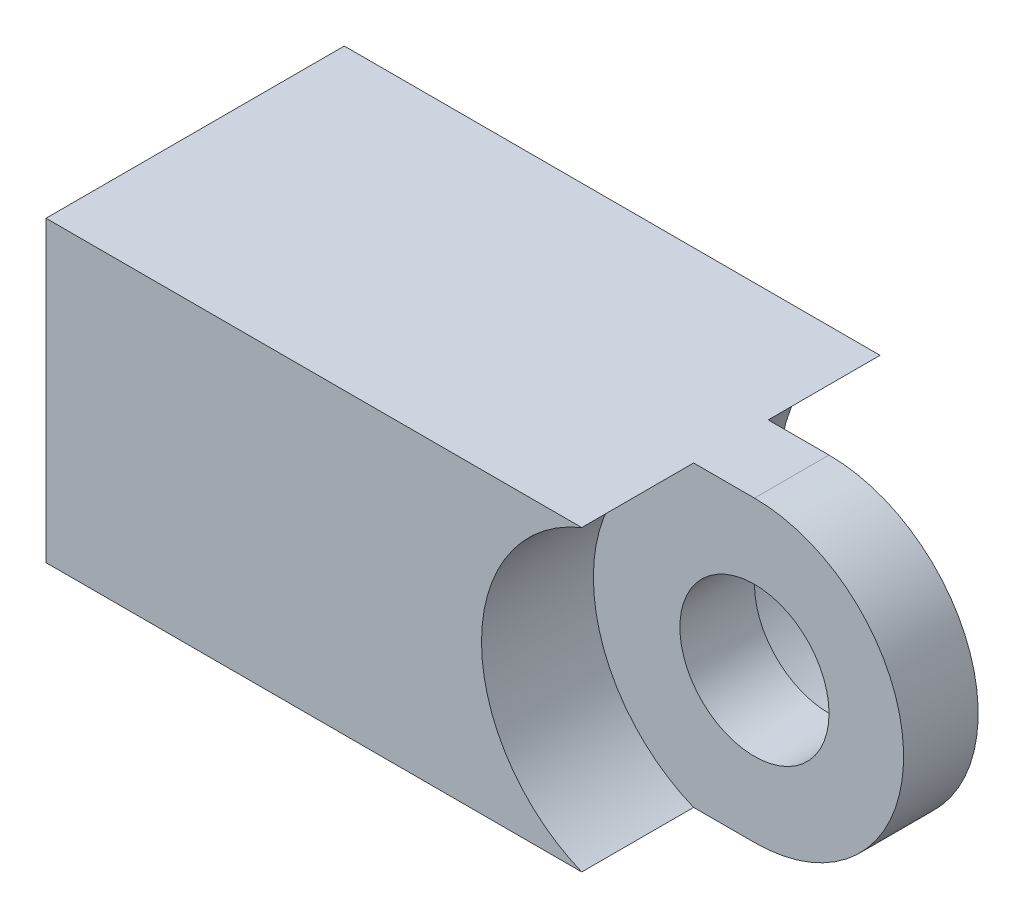
from build123d import *

# Parameters (mm, degrees)
BOSS_EXTRUDE2_DEPTH              = 0.79375
SKETCH4_W                        = 6.35
SKETCH4_H                        = 6.35
BOSS_EXTRUDE3_DEPTH              = 6.35
BOSS_EXTRUDE4_DEPTH              = 3.175
F_4_40_TAPPED_HOLE3_D            = 2.2606
F_4_40_TAPPED_HOLE3_DEPTH        = 8.509
F_4_40_TAPPED_HOLE3_TIP          = 0.679152758
F_1_8_0_125_DIAMETER_HOLE1_D     = 3.175
F_1_8_0_125_DIAMETER_HOLE1_DEPTH = 1.5875


with BuildPart() as part:
    # Sketch2 → Boss-Extrude2 (new body, symmetric)
    with BuildSketch(Plane.XY):
        with BuildLine():
            Line((-6.35, 3.175), (0, 3.175))
            ThreePointArc((0, 3.175), (3.175, 0), (0, -3.175))
            Line((0, -3.175), (-6.35, -3.175))
            Line((-6.35, -3.175), (-6.35, 3.175))
        make_face()
    extrude(amount=BOSS_EXTRUDE2_DEPTH, both=True)

    # Sketch4 → Boss-Extrude3 (add)
    with BuildSketch(Plane.ZY.offset(6.35)):
        Rectangle(SKETCH4_W, SKETCH4_H)
    extrude(amount=BOSS_EXTRUDE3_DEPTH)

    # Sketch10 → Boss-Extrude4 (add, symmetric)
    with BuildSketch(Plane.XY):
        with BuildLine():
            Line((-6.35, 3.175), (-3.175, 3.175))
            Line((-3.175, 3.175), (-1.295150956, 3.175))
            ThreePointArc((-1.295150956, 3.175), (-3.429, 0), (-1.295150956, -3.175))
            Line((-1.295150956, -3.175), (-3.175, -3.175))
            Line((-3.175, -3.175), (-6.35, -3.175))
            Line((-6.35, -3.175), (-6.35, 3.175))
        make_face()
    extrude(amount=BOSS_EXTRUDE4_DEPTH, both=True)

    # #4-40 Tapped Hole3
    with Locations(Plane.ZY.offset(12.7)):
        with Locations((0, 0)):
            Hole(F_4_40_TAPPED_HOLE3_D / 2, depth=F_4_40_TAPPED_HOLE3_DEPTH)
            with Locations((0, 0, -(F_4_40_TAPPED_HOLE3_DEPTH + F_4_40_TAPPED_HOLE3_TIP / 2))):  # 118° drill point
                Cone(0, F_4_40_TAPPED_HOLE3_D / 2, F_4_40_TAPPED_HOLE3_TIP, mode=Mode.SUBTRACT)

    # 1/8 (0.125) Diameter Hole1
    with Locations(Plane.XY.offset(0.79375)):
        with Locations((0, 0)):
            Hole(F_1_8_0_125_DIAMETER_HOLE1_D / 2, depth=F_1_8_0_125_DIAMETER_HOLE1_DEPTH)


solid = part.part
